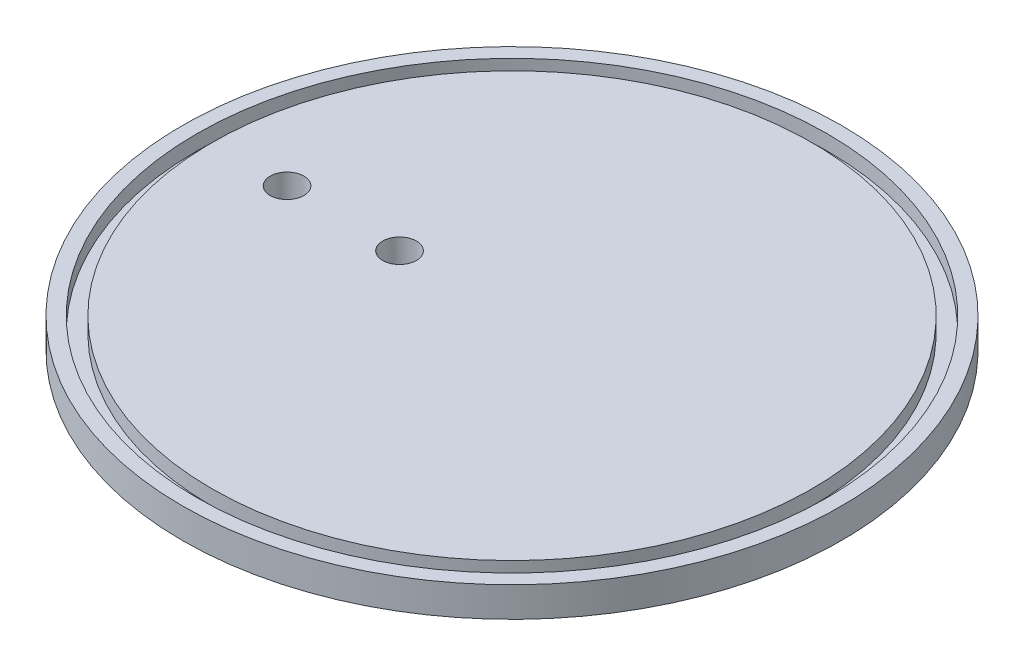
from build123d import *

# Parameters (mm, degrees)
BOSS_EXTRUDE1_DEPTH      = 10
BOSS_EXTRUDE1_DEPTH_BACK = 10
SKETCH4_R                = 2.25
CUT_EXTRUDE1_DEPTH       = 16


with BuildPart() as part:
    # Sketch2 → Revolve1 (revolve)
    with BuildSketch(Plane.XY):
        Polygon((-42.039607805, -2), (-42.039607805, 0), (-43.951704155, 0), (-43.951704155, -4), (-34.016778293, -4), (0, -4), (0, 0), (-40, 0), (-40, -2), align=None)
    revolve(axis=Axis((0, 100, 0), (0, -1, 0)))

    # Sketch3 → Boss-Extrude1 (add, two sides: drawn at the far end of the back side and taken through both)
    with BuildSketch(Plane.XY.offset(-BOSS_EXTRUDE1_DEPTH_BACK)):
        with BuildLine():
            add(Edge.make_bspline(
                [(5, -4), (-2.972410052, -4), (-7.432745191, -9)],
                knots=[1.570796327, 1.570796327, 1.570796327, 2.547844784, 2.547844784, 2.547844784], degree=2, weights=[1, 0.883026434, 1]))
            Line((5, -4), (-35, -4))
            Line((-35, -4), (-35, -9))
            Line((-35, -9), (-7.432745191, -9))
        make_face()
    extrude(amount=BOSS_EXTRUDE1_DEPTH + BOSS_EXTRUDE1_DEPTH_BACK)

    # Sketch4 → Cut-Extrude1 (cut)
    with BuildSketch(Plane.XZ.offset(9)):
        with Locations((-30, 0)):
            Circle(SKETCH4_R)
        with Locations((-15, 0)):
            Circle(SKETCH4_R)
    extrude(amount=-CUT_EXTRUDE1_DEPTH, mode=Mode.SUBTRACT)


solid = part.part
